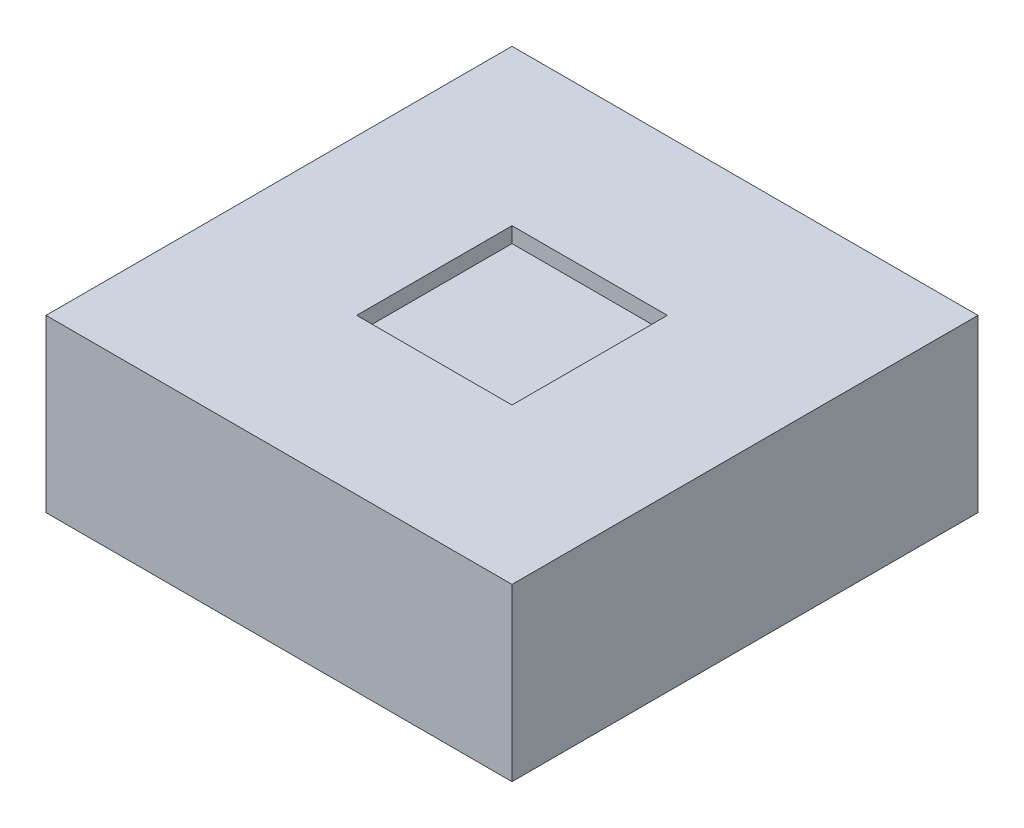
from build123d import *

# Parameters (mm, degrees)
SKETCH1_W           = 30
SKETCH1_H           = 30
BOSS_EXTRUDE1_DEPTH = 10
SKETCH2_W           = 30
SKETCH2_H           = 30
SKETCH2_W_2         = 10
SKETCH2_H_2         = 10
BOSS_EXTRUDE2_DEPTH = 1


with BuildPart() as part:
    # Sketch1 → Boss-Extrude1 (new body)
    with BuildSketch(Plane(origin=(0, 0, 0), x_dir=(1, 0, 0), z_dir=(0, 1, 0))):
        Rectangle(SKETCH1_W, SKETCH1_H)
    extrude(amount=BOSS_EXTRUDE1_DEPTH)

    # Sketch2 → Boss-Extrude2 (add)
    with BuildSketch(Plane(origin=(0, 10, 0), x_dir=(1, 0, 0), z_dir=(0, 1, 0))):
        Rectangle(SKETCH2_W, SKETCH2_H)
        Rectangle(SKETCH2_W_2, SKETCH2_H_2, mode=Mode.SUBTRACT)
    extrude(amount=BOSS_EXTRUDE2_DEPTH)


solid = part.part
